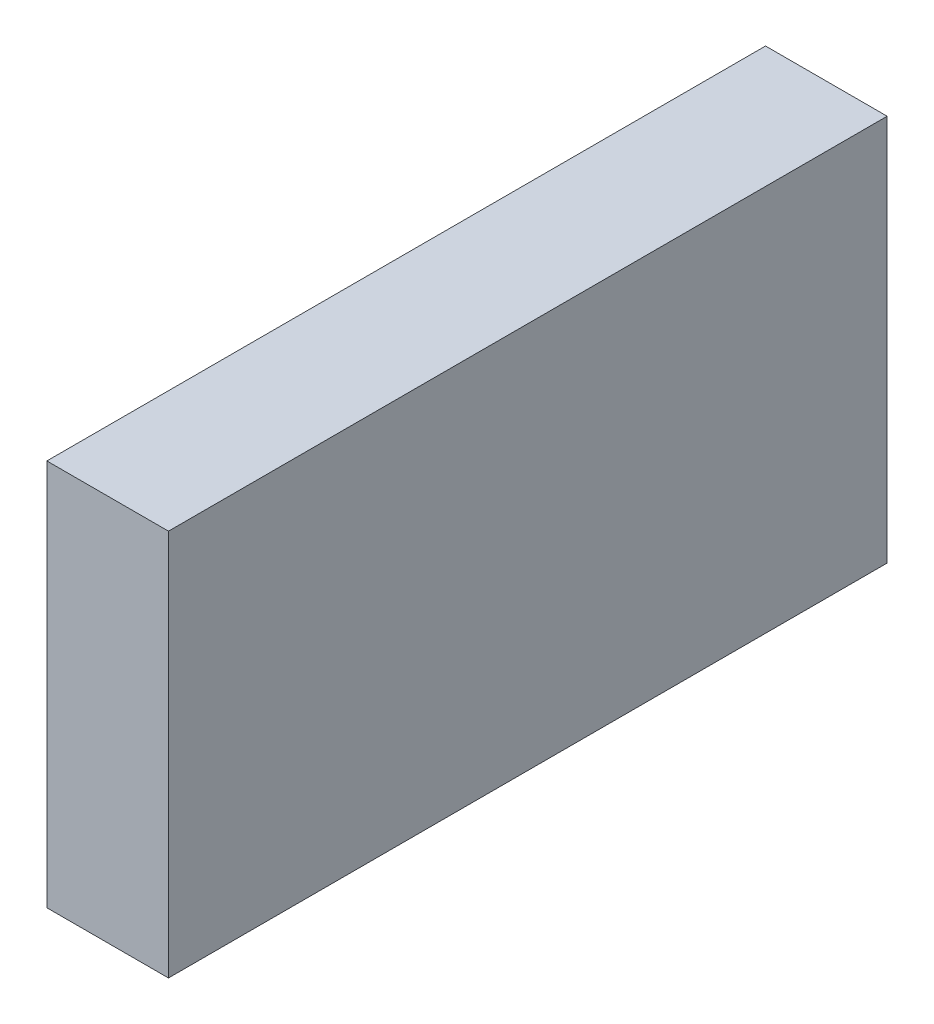
from build123d import *

# Parameters (mm, degrees)
ESQUISSE1_W      = 22
ESQUISSE1_H      = 130
EXTRUSION1_DEPTH = 70


with BuildPart() as part:
    # Esquisse1 → Extrusion1 (new body)
    with BuildSketch(Plane(origin=(0, 0, 0), x_dir=(1, 0, 0), z_dir=(0, 1, 0))):
        with Locations((11, 65)):
            Rectangle(ESQUISSE1_W, ESQUISSE1_H)
    extrude(amount=EXTRUSION1_DEPTH)


solid = part.part
